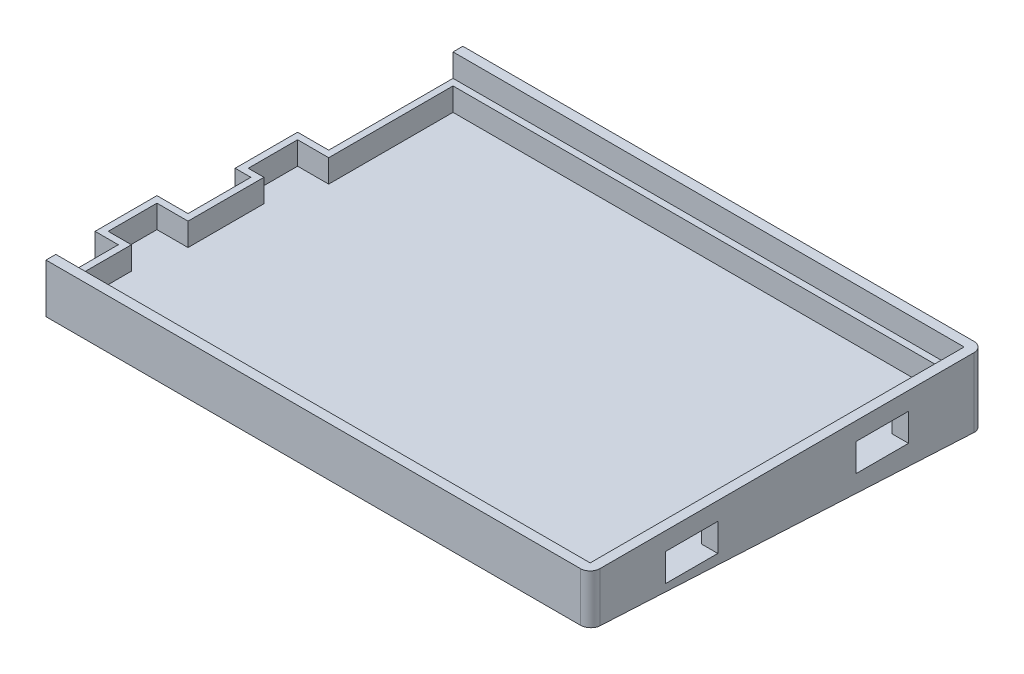
from build123d import *

# Parameters (mm, degrees)
BOSS_EXTRUDE2_DEPTH   = 14
BOSS_EXTRUDE2_2_DEPTH = 14
BOSS_EXTRUDE3_DEPTH   = 1
BOSS_EXTRUDE6_DEPTH   = 159.193
BOSS_EXTRUDE7_DEPTH   = 4.707
BOSS_EXTRUDE8_DEPTH   = 9.5
BOSS_EXTRUDE9_DEPTH   = 7.107
BOSS_EXTRUDE10_DEPTH  = 14.207
SKETCH7_W             = 16
SKETCH7_H             = 8.5
CUT_EXTRUDE1_DEPTH    = 4
FILLET1_R             = 3
FILLET2_R             = 3
SKETCH8_W             = 2
SKETCH8_H             = 42.28
BOSS_EXTRUDE11_DEPTH  = 7
SKETCH9_W             = 16
SKETCH9_H             = 5.5
BOSS_EXTRUDE12_DEPTH  = 3


with BuildPart() as part:
    # Sketch3 → Boss-Extrude2 (new body)
    with BuildSketch(Plane(origin=(0, 0, 0), x_dir=(1, 0, 0), z_dir=(0, 1, 0))):
        Polygon((0, 78.28), (0, 0), (-163.3, 0), (-163.3, -3), (3, -3), (3, 78.28), align=None)
    extrude(amount=BOSS_EXTRUDE2_DEPTH)

    # Sketch3_3 → Boss-Extrude3 (add)
    with BuildSketch(Plane(origin=(0, 0, 0), x_dir=(1, 0, 0), z_dir=(0, 1, 0))):
        Polygon((-163.3, 19.1), (-163.3, -3), (3, -3), (3, 78.28), (0, 78.28), (0, 114.28), (-156.193, 114.28), (-156.193, 76.28), (-165.693, 76.28), (-165.693, 57.2), (-160.9, 57.2), (-160.9, 38), (-170.4, 38), (-170.4, 19.1), align=None)
    extrude(amount=-BOSS_EXTRUDE3_DEPTH)



with BuildPart() as body_2:
    # Sketch3 → Boss-Extrude2 2 (new body)
    with BuildSketch(Plane(origin=(0, 0, 0), x_dir=(1, 0, 0), z_dir=(0, 1, 0))):
        Polygon((0, 114.28), (0, 94.28), (3, 94.28), (3, 117.28), (-156.193, 117.28), (-156.193, 114.28), align=None)
    extrude(amount=BOSS_EXTRUDE2_2_DEPTH)


with BuildPart() as part_1:
    add(part.part)

    add(body_2.part)  # Boss-Extrude6 merges body 2
    # Sketch4 → Boss-Extrude6 (add)
    with BuildSketch(Plane(origin=(3, 0, 0), x_dir=(0, 0, -1), z_dir=(1, 0, 0))):
        Polygon((-3, -1), (117.28, -7.303607692), (117.28, 0), (-3, 0), align=None)
    extrude(amount=-BOSS_EXTRUDE6_DEPTH)

    # Sketch5 → Boss-Extrude7 (add)
    with BuildSketch(Plane.ZY.offset(156.193)):
        Polygon((-38, 0), (-57.2, 0), (-57.2, -4.154948313), (-38, -3.148718951), align=None)
    extrude(amount=BOSS_EXTRUDE7_DEPTH)

    # Sketch5_4 → Boss-Extrude8 (add)
    with BuildSketch(Plane.ZY.offset(156.193)):
        Polygon((-57.2, 0), (-76.28, 0), (-76.28, -5.154888742), (-57.2, -4.154948313), align=None)
    extrude(amount=BOSS_EXTRUDE8_DEPTH)

    # Sketch5 again → Boss-Extrude9 (add)
    with BuildSketch(Plane.ZY.offset(156.193)):
        Polygon((3, -1), (-19.1, -1), (-19.1, -2.158211922), align=None)
    extrude(amount=BOSS_EXTRUDE9_DEPTH)

    # Sketch5_6 → Boss-Extrude10 (add)
    with BuildSketch(Plane.ZY.offset(156.193)):
        Polygon((-19.1, -1), (-38, -1), (-38, -3.148718951), (-19.1, -2.158211922), align=None)
    extrude(amount=BOSS_EXTRUDE10_DEPTH)

    # Sketch7 → Cut-Extrude1 (cut)
    with BuildSketch(Plane.ZY):
        with Locations((-28, 4.25)):
            Rectangle(SKETCH7_W, SKETCH7_H)
    extrude(amount=-CUT_EXTRUDE1_DEPTH, mode=Mode.SUBTRACT)

    # Fillet1
    fillet1_edges = [part_1.edges().sort_by_distance(p)[0] for p in [
        (3, 3.348196154, -117.28),
    ]]
    fillet(fillet1_edges, radius=FILLET1_R)

    # Fillet2
    fillet2_edges = [part_1.edges().sort_by_distance(p)[0] for p in [
        (3, 6.5, 3),
    ]]
    fillet(fillet2_edges, radius=FILLET2_R)

    # Sketch8 → Boss-Extrude11 (add)
    with BuildSketch(Plane(origin=(0, 0, 0), x_dir=(1, 0, 0), z_dir=(0, 1, 0))):
        Polygon((-154.193, 112.28), (-2, 112.28), (-2, 94.28), (0, 94.28), (0, 114.28), (-156.193, 114.28), (-156.193, 76.28), (-165.693, 76.28), (-165.693, 57.2), (-160.9, 57.2), (-160.9, 38), (-170.4, 38), (-170.4, 19.1), (-163.3, 19.1), (-163.3, 0), (0, 0), (0, 20), (-2, 20), (-2, 2), (-161.3, 2), (-161.3, 21.1), (-168.4, 21.1), (-168.4, 36), (-158.9, 36), (-158.9, 59.2), (-163.693, 59.2), (-163.693, 74.28), (-154.193, 74.28), align=None)
        with Locations((-1, 57.14)):
            Rectangle(SKETCH8_W, SKETCH8_H)
    extrude(amount=BOSS_EXTRUDE11_DEPTH)

    # Sketch9 → Boss-Extrude12 (add)
    with BuildSketch(Plane.ZY):
        with Locations((-86.28, 11.25)):
            Rectangle(SKETCH9_W, SKETCH9_H)
    extrude(amount=-BOSS_EXTRUDE12_DEPTH)


solid = part_1.part
